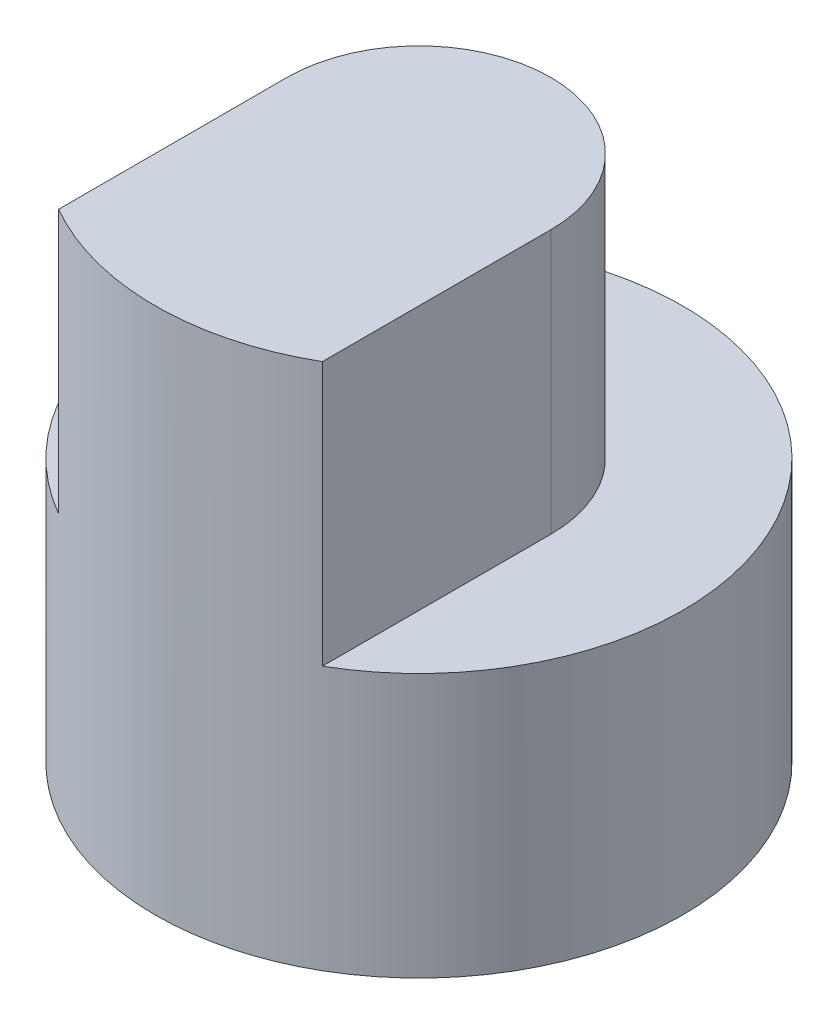
from build123d import *

# Parameters (mm, degrees)
SKETCH1_R           = 2
BOSS_EXTRUDE1_DEPTH = 2
BOSS_EXTRUDE2_DEPTH = 2


with BuildPart() as part:
    # Sketch1 → Boss-Extrude1 (new body)
    with BuildSketch(Plane(origin=(0, 0, 0), x_dir=(1, 0, 0), z_dir=(0, 1, 0))):
        Circle(SKETCH1_R)
    extrude(amount=BOSS_EXTRUDE1_DEPTH)

    # Sketch2 → Boss-Extrude2 (add)
    with BuildSketch(Plane(origin=(0, 2, 0), x_dir=(1, 0, 0), z_dir=(0, 1, 0))):
        with BuildLine():
            Line((-1, -1.732050808), (-1, 0))
            ThreePointArc((-1, 0), (0, 1), (1, 0))
            Line((1, 0), (1, -1.732050808))
            ThreePointArc((1, -1.732050808), (0, -2), (-1, -1.732050808))
        make_face()
    extrude(amount=BOSS_EXTRUDE2_DEPTH)


solid = part.part
